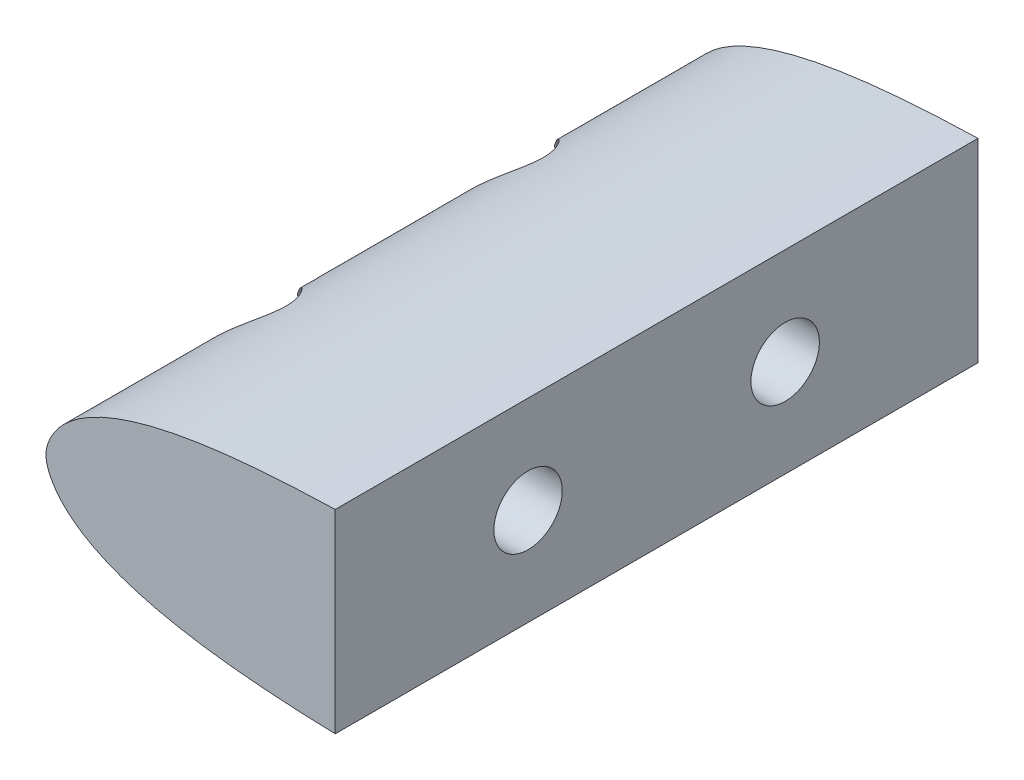
from build123d import *

# Parameters (mm, degrees)
BOSS_EXTRUDE1_DEPTH                           = 63.5
CBORE_FOR_1_4_SOCKET_HEAD_CAP_SCREW1_AT_COUNT = 2
CBORE_FOR_1_4_SOCKET_HEAD_CAP_SCREW1_AT_PITCH = 25.4


with BuildPart() as part:
    # Sketch2 → Boss-Extrude1 (new body)
    with BuildSketch(Plane.XY):
        with BuildLine():
            Line((28.575, 9.600693743), (28.575, -9.600693743))
            add(Edge.make_bspline(
                [(28.575, 9.600693743), (28.310401864, 9.593474335), (26.722184431, 9.546895018), (23.80909263, 9.423916942), (19.83652587, 9.137555224), (16.126941466, 8.724596023), (12.680513312, 8.159487318), (10.032530426, 7.556873589), (7.922127502, 6.918815912), (6.324809311, 6.335015586), (4.718104282, 5.602959138), (3.08294517, 4.643752576), (1.726538443, 3.521961778), (0.531933312, 2.020395179), (-0.347353812, 0), (0.531933312, -2.020395179), (1.726538443, -3.521961778), (3.08294517, -4.643752576), (4.718104282, -5.602959138), (6.324809311, -6.335015586), (7.922127502, -6.918815912), (10.032530426, -7.556873589), (12.680513312, -8.159487318), (16.126941466, -8.724596023), (19.83652587, -9.137555224), (23.80909263, -9.423916942), (26.722184431, -9.546895018), (28.310401864, -9.593474335), (28.575, -9.600693743)],
                knots=[0.401740762, 0.401740762, 0.401740762, 0.401740762, 0.404182653, 0.416398684, 0.428636132, 0.440920171, 0.450818129, 0.460843203, 0.465945571, 0.471149096, 0.476522598, 0.482208155, 0.488618357, 0.492567758, 0.5, 0.507432242, 0.511381643, 0.517791845, 0.523477402, 0.528850904, 0.534054429, 0.539156797, 0.549181871, 0.559079829, 0.571363868, 0.583601316, 0.595817347, 0.598259238, 0.598259238, 0.598259238, 0.598259238], degree=3))
        make_face()
    extrude(amount=BOSS_EXTRUDE1_DEPTH)

    # Sketch5 → CBORE for 1/4 Socket Head Cap Screw1 (revolve, cut)
    with BuildSketch(Plane(origin=(0, 0, 19.05), x_dir=(0, 0, 1), z_dir=(0, 1, 0))):
        Polygon((0, 0), (0, 28.575), (3.3782, 28.575), (3.3782, 6.35), (5.55625, 6.35), (5.55625, 0.532828266), (6.19125, 0), align=None)
    cbore_for_1_4_socket_head_cap_screw1 = revolve(axis=Axis((-6.35, 0, 19.05), (1, 0, 0)), mode=Mode.SUBTRACT)

    # CBORE for 1/4 Socket Head Cap Screw1 at: CBORE for 1/4 Socket Head Cap Screw1 ×2
    with Locations(*[(0, 0, i * CBORE_FOR_1_4_SOCKET_HEAD_CAP_SCREW1_AT_PITCH) for i in range(1, CBORE_FOR_1_4_SOCKET_HEAD_CAP_SCREW1_AT_COUNT)]):
        add(cbore_for_1_4_socket_head_cap_screw1, mode=Mode.SUBTRACT)


solid = part.part
